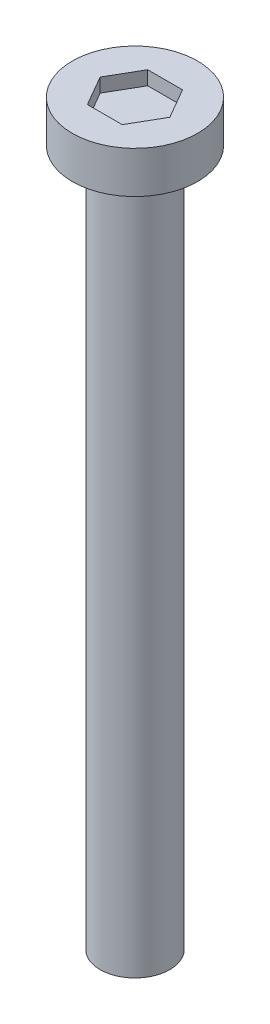
from build123d import *

# Parameters (mm, degrees)
SKETCH1_R           = 1.25
BOSS_EXTRUDE1_DEPTH = 25
SKETCH4_R           = 2.25
BOSS_EXTRUDE2_DEPTH = 1.5
CUT_EXTRUDE1_DEPTH  = 0.5


with BuildPart() as part:
    # Sketch1 → Boss-Extrude1 (new body)
    with BuildSketch(Plane(origin=(0, 0, 0), x_dir=(1, 0, 0), z_dir=(0, 1, 0))):
        Circle(SKETCH1_R)
    extrude(amount=BOSS_EXTRUDE1_DEPTH)

    # Sketch4 → Boss-Extrude2 (add)
    with BuildSketch(Plane(origin=(0, 25, 0), x_dir=(1, 0, 0), z_dir=(0, 1, 0))):
        Circle(SKETCH4_R)
    extrude(amount=BOSS_EXTRUDE2_DEPTH)

    # Sketch5 → Cut-Extrude1 (cut)
    with BuildSketch(Plane(origin=(0, 26.5, 0), x_dir=(1, 0, 0), z_dir=(0, 1, 0))):
        Polygon((1.25, 0), (0.625, 1.082531755), (-0.625, 1.082531755), (-1.25, 0), (-0.625, -1.082531755), (0.625, -1.082531755), align=None)
    extrude(amount=-CUT_EXTRUDE1_DEPTH, mode=Mode.SUBTRACT)


solid = part.part
